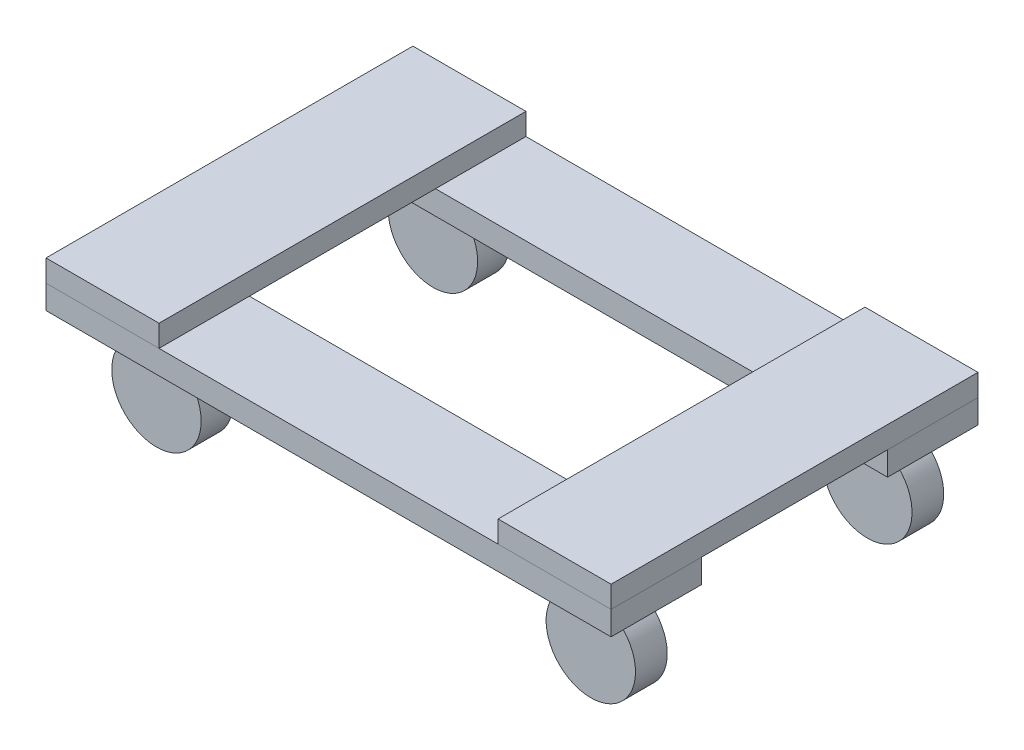
from build123d import *

# Parameters (mm, degrees)
SKETCH1_W                  = 452.4375
SKETCH1_H                  = 72.39
BOSS_EXTRUDE1_DEPTH        = 19.05
BOSS_EXTRUDE1_2_DEPTH      = 19.05
SKETCH2_W                  = 90.4875
SKETCH2_H                  = 293.781971524
BOSS_EXTRUDE2_DEPTH        = 17.4625
BOSS_EXTRUDE2_2_DEPTH      = 17.4625
SKETCH3_R                  = 35.789243898
BOSS_EXTRUDE3_DEPTH        = 12.7
BOSS_EXTRUDE3_DEPTH_BACK   = 12.7
BOSS_EXTRUDE3_2_DEPTH      = 12.7
BOSS_EXTRUDE3_2_DEPTH_BACK = 12.7
SKETCH4_R                  = 35.789243898
BOSS_EXTRUDE4_DEPTH        = 12.7
BOSS_EXTRUDE4_DEPTH_BACK   = 12.7
BOSS_EXTRUDE4_2_DEPTH      = 12.7
BOSS_EXTRUDE4_2_DEPTH_BACK = 12.7


with BuildPart() as part:
    # Sketch1 → Boss-Extrude1 (new body)
    with BuildSketch(Plane(origin=(0, 0, 0), x_dir=(1, 0, 0), z_dir=(0, 1, 0))):
        with Locations((226.21875, 36.195)):
            Rectangle(SKETCH1_W, SKETCH1_H)
    extrude(amount=BOSS_EXTRUDE1_DEPTH)


with BuildPart() as body_2:
    # Sketch1 → Boss-Extrude1 2 (new body)
    with BuildSketch(Plane(origin=(0, 0, 0), x_dir=(1, 0, 0), z_dir=(0, 1, 0))):
        with Locations((226.21875, -185.196971524)):
            Rectangle(SKETCH1_W, SKETCH1_H)
    extrude(amount=BOSS_EXTRUDE1_2_DEPTH)


with BuildPart() as body_3:
    # Sketch2 → Boss-Extrude2 (new body)
    with BuildSketch(Plane(origin=(0, 19.05, 0), x_dir=(1, 0, 0), z_dir=(0, 1, 0))):
        with Locations((407.19375, -74.500985762)):
            Rectangle(SKETCH2_W, SKETCH2_H)
    extrude(amount=BOSS_EXTRUDE2_DEPTH)


with BuildPart() as body_4:
    # Sketch2 → Boss-Extrude2 2 (new body)
    with BuildSketch(Plane(origin=(0, 19.05, 0), x_dir=(1, 0, 0), z_dir=(0, 1, 0))):
        with Locations((45.24375, -74.500985762)):
            Rectangle(SKETCH2_W, SKETCH2_H)
    extrude(amount=BOSS_EXTRUDE2_2_DEPTH)


with BuildPart() as body_5:
    # Sketch3 → Boss-Extrude3 (new body, two sides)
    with BuildSketch(Plane.XY.offset(185.196971524)) as boss_extrude3_sk:
        with Locations((64.941566703, -38.090416539)):
            Circle(SKETCH3_R)
    extrude(amount=BOSS_EXTRUDE3_DEPTH)
    extrude(boss_extrude3_sk.sketch, amount=-BOSS_EXTRUDE3_DEPTH_BACK)


with BuildPart() as body_6:
    # Sketch3 → Boss-Extrude3 2 (new body, two sides)
    with BuildSketch(Plane.XY.offset(185.196971524)) as boss_extrude3_2_sk:
        with Locations((412.709416413, -38.090416539)):
            Circle(SKETCH3_R)
    extrude(amount=BOSS_EXTRUDE3_2_DEPTH)
    extrude(boss_extrude3_2_sk.sketch, amount=-BOSS_EXTRUDE3_2_DEPTH_BACK)


with BuildPart() as body_7:
    # Sketch4 → Boss-Extrude4 (new body, two sides)
    with BuildSketch(Plane(origin=(0, 0, -36.195), x_dir=(-1, 0, 0), z_dir=(0, 0, -1))) as boss_extrude4_sk:
        with Locations((-64.941566703, -38.090416539)):
            Circle(SKETCH4_R)
    extrude(amount=BOSS_EXTRUDE4_DEPTH)
    extrude(boss_extrude4_sk.sketch, amount=-BOSS_EXTRUDE4_DEPTH_BACK)


with BuildPart() as body_8:
    # Sketch4 → Boss-Extrude4 2 (new body, two sides)
    with BuildSketch(Plane(origin=(0, 0, -36.195), x_dir=(-1, 0, 0), z_dir=(0, 0, -1))) as boss_extrude4_2_sk:
        with Locations((-412.709416413, -38.090416539)):
            Circle(SKETCH4_R)
    extrude(amount=BOSS_EXTRUDE4_2_DEPTH)
    extrude(boss_extrude4_2_sk.sketch, amount=-BOSS_EXTRUDE4_2_DEPTH_BACK)


solid = Compound([part.part, body_2.part, body_3.part, body_4.part, body_5.part, body_6.part, body_7.part, body_8.part])
